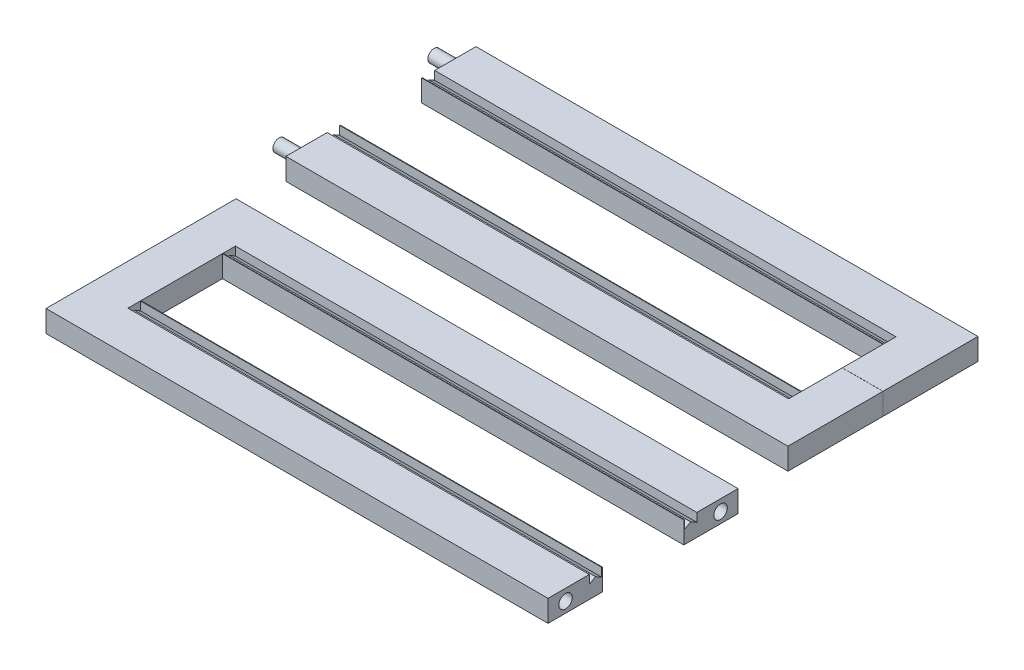
from build123d import *

# Parameters (mm, degrees)
BOSS_EXTRUDE1_DEPTH      = 10.16
CUT_EXTRUDE1_DEPTH       = 469.9
SKETCH7_W                = 12.402912868
SKETCH7_H                = 5.692085864
BOSS_EXTRUDE2_DEPTH      = 19.05
SKETCH8_W                = 44.473666897
SKETCH8_H                = 10.16
BOSS_EXTRUDE3_DEPTH      = 19.05
SKETCH11_R               = 5.7912
CUT_EXTRUDE2_DEPTH       = 3.81
SURFACE_EXTRUDE1_1_BACK  = 127
SURFACE_EXTRUDE1_1_DEPTH = 127
SURFACE_EXTRUDE1_2_BACK  = 127
SURFACE_EXTRUDE1_2_DEPTH = 127
SKETCH13_R               = 3.158479385
CUT_EXTRUDE3_DEPTH       = 12.7
SKETCH15_R               = 2.910262426
BOSS_EXTRUDE6_DEPTH      = 11.43
SKETCH16_R               = 2.915718577
BOSS_EXTRUDE7_DEPTH      = 11.43
SKETCH17_R               = 3.139130121
CUT_EXTRUDE4_DEPTH       = 12.7


with BuildPart() as part:
    # Sketch1 → Boss-Extrude1 (new body)
    with BuildSketch(Plane(origin=(0, 0, 0), x_dir=(1, 0, 0), z_dir=(0, 1, 0))):
        Polygon((16.038025544, 57.472460937), (-434.826171875, 57.472460937), (-434.826171875, 13.022460937), (-415.790369294, 13.022460937), (-415.790369294, 32.072460937), (16.038025544, 32.072460938), align=None)
        Polygon((35.073828125, 57.472460938), (16.038025544, 57.472460937), (16.038025544, 32.072460938), (16.038025544, 13.022460938), (35.073828125, 13.022460938), align=None)
    extrude(amount=BOSS_EXTRUDE1_DEPTH)

    # Sketch3 → Cut-Extrude1 (cut)
    with BuildSketch(Plane(origin=(35.073828125, 0, 0), x_dir=(0, 0, -1), z_dir=(1, 0, 0))):
        Polygon((38.155998325, 6.152693314), (38.155998325, 10.16), (32.33892355, 10.16), (32.33892355, 6.152693314), (35.247460938, 7.831938158), align=None)
    extrude(amount=-CUT_EXTRUDE1_DEPTH, mode=Mode.SUBTRACT)

    # Sketch7 → Boss-Extrude2 (add)
    with BuildSketch(Plane(origin=(35.073828125, 0, 0), x_dir=(0, 0, -1), z_dir=(1, 0, 0))):
        with Locations((34.557393907, 7.313957068)):
            Rectangle(SKETCH7_W, SKETCH7_H)
    extrude(amount=-BOSS_EXTRUDE2_DEPTH)

    # Sketch8 → Boss-Extrude3 (add)
    with BuildSketch(Plane.ZY.offset(434.826171875)):
        with Locations((-35.23562749, 5.08)):
            Rectangle(SKETCH8_W, SKETCH8_H)
    extrude(amount=-BOSS_EXTRUDE3_DEPTH)

    # Mirror1: part across plane


with BuildPart() as part_1:
    add(part.part)
    add(part.part.mirror(Plane(origin=(-415.776171875, 10.16, -12.998794041), x_dir=(1, 0, 0), z_dir=(0, 0, 1))))

    # Sketch11 → Cut-Extrude2 (cut)
    with BuildSketch(Plane.XZ):
        with Locations(Location((-425.156251148, 10.226790326, 0), (0, 0, 270))):
            Circle(SKETCH11_R)
        with Locations(Location((25.403907398, -36.248045304, 0), (0, 0, 270))):
            Circle(SKETCH11_R)
        with Locations(Location((25.403907398, 10.226790326, 0), (0, 0, 270))):
            Circle(SKETCH11_R)
        with Locations(Location((-425.156251148, -36.248045304, 0), (0, 0, 270))):
            Circle(SKETCH11_R)
    extrude(amount=-CUT_EXTRUDE2_DEPTH, mode=Mode.SUBTRACT)


with BuildPart() as body_2:
    # Split1: the piece behind the surface
    add(part_1.part)
    # Surface-Extrude1: a surface, the sketch's curves swept straight by 127 mm
    with BuildLine(Plane.XY.offset(31.474872855).offset(-SURFACE_EXTRUDE1_1_BACK), mode=Mode.PRIVATE) as surface_extrude1_1_path:
        Line((-199.876171875, -28.692285392), (-199.876171875, 81.458221416))
    surface_extrude1_1 = Shell.extrude(surface_extrude1_1_path.wire(), (0 * SURFACE_EXTRUDE1_1_DEPTH, 0 * SURFACE_EXTRUDE1_1_DEPTH, 1 * SURFACE_EXTRUDE1_1_DEPTH))
    split(bisect_by=surface_extrude1_1, keep=Keep.BOTTOM)

    # Sketch15 → Boss-Extrude6 (add)
    with BuildSketch(Plane.ZY.offset(199.876171875)):
        with Locations((-49.260284321, 4.9038256)):
            Circle(SKETCH15_R)
    extrude(amount=BOSS_EXTRUDE6_DEPTH)

    # Sketch16 → Boss-Extrude7 (add)
    with BuildSketch(Plane.ZY.offset(199.876171875)):
        with Locations((23.262696239, 4.9038256)):
            Circle(SKETCH16_R)
    extrude(amount=BOSS_EXTRUDE7_DEPTH)


with BuildPart() as part_2:
    add(part_1.part)

    # Split1: split by a surface, the side it looks to stays
    # Surface-Extrude1: a surface, the sketch's curves swept straight by 127 mm
    with BuildLine(Plane.XY.offset(31.474872855).offset(-SURFACE_EXTRUDE1_2_BACK), mode=Mode.PRIVATE) as surface_extrude1_2_path:
        Line((-199.876171875, -28.692285392), (-199.876171875, 81.458221416))
    surface_extrude1_2 = Shell.extrude(surface_extrude1_2_path.wire(), (0 * SURFACE_EXTRUDE1_2_DEPTH, 0 * SURFACE_EXTRUDE1_2_DEPTH, 1 * SURFACE_EXTRUDE1_2_DEPTH))
    split(bisect_by=surface_extrude1_2, keep=Keep.TOP)


with BuildPart() as part_3:
    # Body-Move/Copy1: moved
    add(part_2.part.moved(Location((240.476626778, 0, 117.80977063))))

    # Sketch13 → Cut-Extrude3 (cut)
    with BuildSketch(Plane(origin=(40.600454903, 0, 0), x_dir=(0, 0, -1), z_dir=(1, 0, 0))):
        with Locations((-68.549486363, 4.903834039)):
            Circle(SKETCH13_R)
    extrude(amount=-CUT_EXTRUDE3_DEPTH, mode=Mode.SUBTRACT)

    # Sketch17 → Cut-Extrude4 (cut)
    with BuildSketch(Plane(origin=(40.600454903, 0, 0), x_dir=(0, 0, -1), z_dir=(1, 0, 0))):
        with Locations((-141.072466869, 4.9038256)):
            Circle(SKETCH17_R)
    extrude(amount=-CUT_EXTRUDE4_DEPTH, mode=Mode.SUBTRACT)


solid = Compound([body_2.part, part_3.part])
